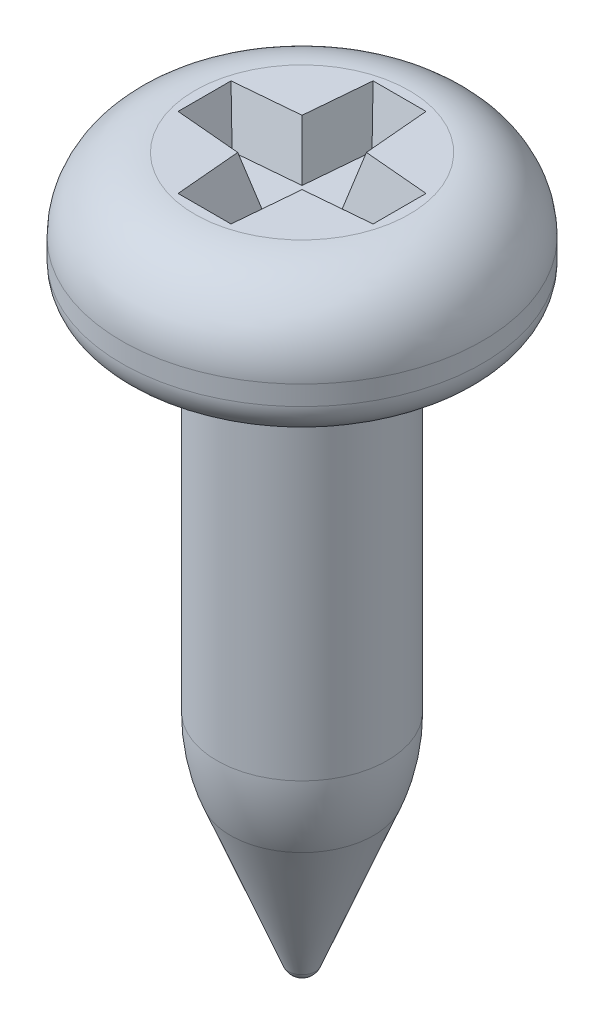
from build123d import *

# Parameters (mm, degrees)
CUT_EXTRUDE1_DEPTH = 0.5
CUT_EXTRUDE1_TAPER = 15


with BuildPart() as part:
    # Sketch1 → Revolve1 (revolve)
    with BuildSketch(Plane.XY):
        with BuildLine():
            Line((0.875, -4.964405423), (0.875, -1.45))
            ThreePointArc((0.875, -1.45), (0.918933983, -1.343933983), (1.025, -1.3))
            Line((1.025, -1.3), (1.5, -1.3))
            ThreePointArc((1.5, -1.3), (1.747487373, -1.197487373), (1.85, -0.95))
            Line((1.85, -0.95), (1.85, -0.75))
            ThreePointArc((1.85, -0.75), (1.630330086, -0.219669914), (1.1, 0))
            Line((1.1, 0), (0, 0))
            Line((0, 0), (0, -7.3))
            ThreePointArc((0, -7.3), (0.084334338, -7.274047247), (0.139485899, -7.205169593))
            Line((0.139485899, -7.205169593), (0.734811985, -5.7))
            ThreePointArc((0.734811985, -5.7), (0.839640421, -5.338822324), (0.875, -4.964405423))
        make_face()
    revolve(axis=Axis((0, 0, 0), (0, -1, 0)))

    # Sketch2 → Cut-Extrude1 (cut)
    with BuildSketch(Plane(origin=(0, 0, 0), x_dir=(1, 0, 0), z_dir=(0, 1, 0))):
        Polygon((-0.271382595, 1), (-0.33, 0.33), (-1, 0.271382595), (-1, -0.271382595), (-0.33, -0.33), (-0.271382595, -1), (0.271382595, -1), (0.33, -0.33), (1, -0.271382595), (1, 0.271382595), (0.33, 0.33), (0.271382595, 1), align=None)
    extrude(amount=-CUT_EXTRUDE1_DEPTH, taper=CUT_EXTRUDE1_TAPER, mode=Mode.SUBTRACT)


solid = part.part
